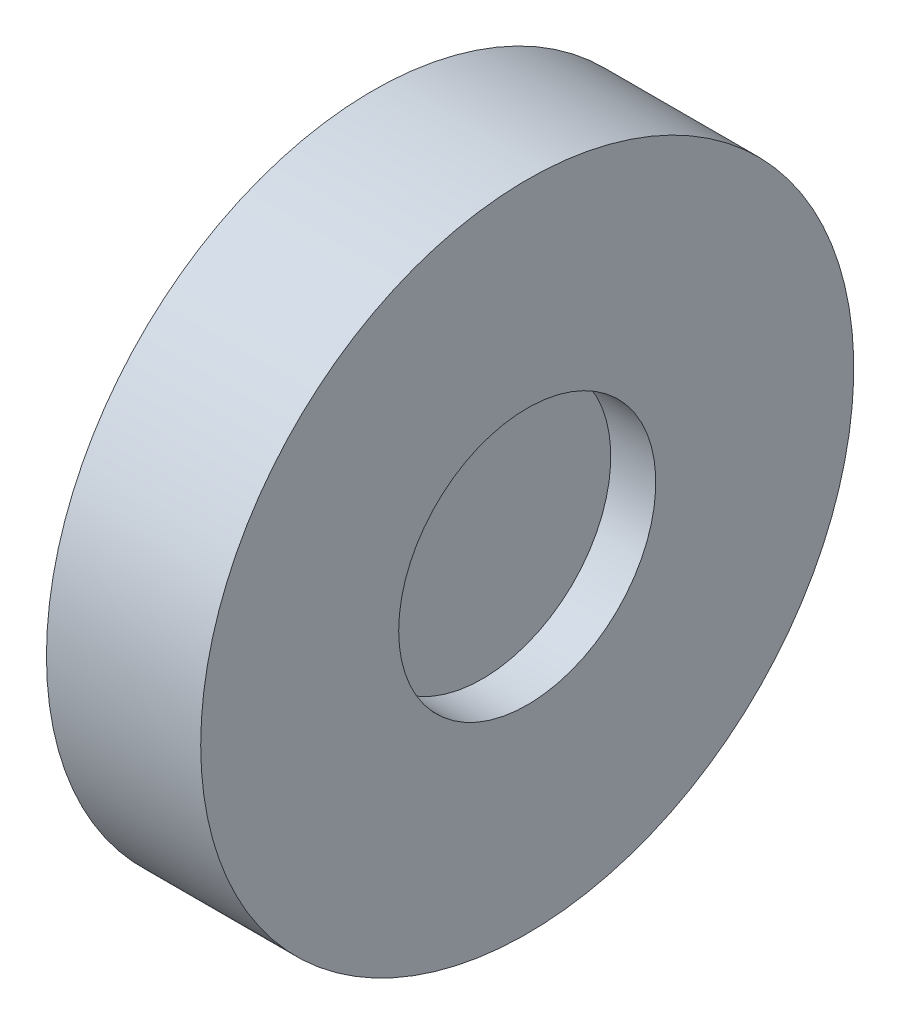
from build123d import *

# Parameters (mm, degrees)
SKETCH_1_W = 2.5
SKETCH_1_H = 5
SKETCH_4_W = 6
SKETCH_4_H = 7.7


with BuildPart() as part:
    # 草图1 → 旋转2 (revolve)
    with BuildSketch(Plane.XY, mode=Mode.PRIVATE) as revolve_2_sk:
        with Locations((0, 2.5)):
            Rectangle(SKETCH_1_W, SKETCH_1_H)
    revolve(revolve_2_sk.sketch.rotate(Axis((-1.25, 0, 0), (1, 0, 0)), 90), axis=Axis((-1.25, 0, 0), (1, 0, 0)))  # turned: the seam where the file's is

    # 草图4 → 旋转3 (revolve)
    with BuildSketch(Plane.XY, mode=Mode.PRIVATE) as revolve_3_sk:
        with Locations((0, 8.85)):
            Rectangle(SKETCH_4_W, SKETCH_4_H)
    revolve(revolve_3_sk.sketch.rotate(Axis((-1.614212419, 0, 0), (1, 0, 0)), 90), axis=Axis((-1.614212419, 0, 0), (1, 0, 0)))  # turned: the seam where the file's is


solid = part.part
